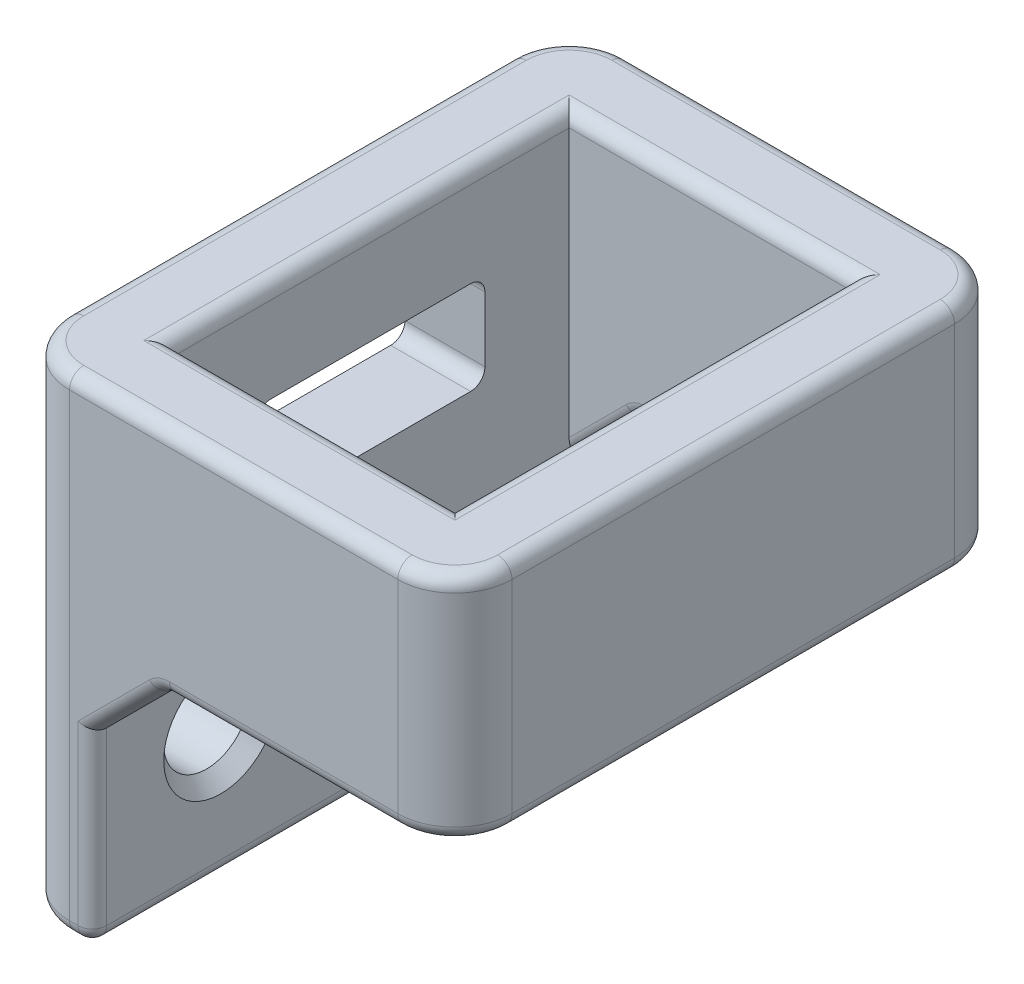
from build123d import *

# Parameters (mm, degrees)
SKETCH1_W                      = 15.5
SKETCH1_H                      = 19.5
SKETCH1_W_2                    = 9.9
SKETCH1_H_2                    = 13.9
BOSS_EXTRUDE1_DEPTH            = 4.05
SKETCH2_W                      = 19.5
SKETCH2_H                      = 9
SKETCH2_R                      = 1.5
BOSS_EXTRUDE2_DEPTH            = 2.8
CHAMFER1_SIZE                  = 2.5
FILLET1_R                      = 2
FILLET2_R                      = 0.5
CHAMFER2_SIZE                  = 0.5
CUT_EXTRUDE1_DEPTH             = 1.0000001
CUT_EXTRUDE1_DIRECTION_2_REACH = 17.5


with BuildPart() as part:
    # Sketch1 → Boss-Extrude1 (new body, symmetric)
    with BuildSketch(Plane(origin=(0, 0, 0), x_dir=(1, 0, 0), z_dir=(0, 1, 0))):
        Rectangle(SKETCH1_W, SKETCH1_H)
        Rectangle(SKETCH1_W_2, SKETCH1_H_2, mode=Mode.SUBTRACT)
    extrude(amount=BOSS_EXTRUDE1_DEPTH, both=True)

    # Sketch2 → Boss-Extrude2 (add)
    with BuildSketch(Plane.ZY.offset(7.75)):
        with Locations((0, -8.55)):
            Rectangle(SKETCH2_W, SKETCH2_H)
        with Locations((-5.25, -8.55)):
            Circle(SKETCH2_R, mode=Mode.SUBTRACT)
        with Locations((5.25, -8.55)):
            Circle(SKETCH2_R, mode=Mode.SUBTRACT)
    extrude(amount=-BOSS_EXTRUDE2_DEPTH)

    # Chamfer1
    chamfer1_edges = [part.edges().sort_by_distance(p)[0] for p in [
        (-4.95, -4.05, -8.35),
        (-4.95, -4.05, 8.35),
    ]]
    chamfer(chamfer1_edges, length=CHAMFER1_SIZE)

    # Fillet1
    fillet1_edges = [part.edges().sort_by_distance(p)[0] for p in [
        (-7.75, -4.5, -9.75),
        (7.75, 0, -9.75),
        (7.75, 0, 9.75),
        (-7.75, -4.5, 9.75),
    ]]
    fillet(fillet1_edges, radius=FILLET1_R)

    # Fillet2
    fillet2_edges = [part.edges().sort_by_distance(p)[0] for p in [
        (4.95, -4.05, 0),
        (1.25, -4.05, -6.95),
        (-4.95, 4.05, 0),
        (0, 4.05, 6.95),
        (4.95, 4.05, 0),
        (0, 4.05, -6.95),
        (-5.35, -13.05, -9.75),
        (-4.95, -9.8, 9.75),
        (-4.95, -13.05, 0),
        (-5.35, -13.05, 9.75),
        (1.65, -4.05, 9.75),
        (1.25, -4.05, 6.95),
        (-2.45, -4.05, 8.35),
        (-2.45, -4.05, -8.35),
        (-4.95, -9.8, -9.75),
        (-3.7, -5.3, -9.75),
        (-3.7, -5.3, -6.95),
        (-3.7, -5.3, 6.95),
        (-3.7, -5.3, 9.75),
        (1.65, -4.05, -9.75),
        (0, 4.05, -9.75),
        (7.75, -4.05, 0),
        (7.164213562, -4.05, 9.164213562),
        (7.164213562, -4.05, -9.164213562),
        (7.75, 4.05, 0),
        (-7.75, 4.05, 0),
        (0, 4.05, 9.75),
        (-7.164213562, 4.05, 9.164213562),
        (-7.164213562, 4.05, -9.164213562),
        (7.164213562, 4.05, 9.164213562),
        (7.164213562, 4.05, -9.164213562),
        (-7.75, -13.05, 0),
        (-7.164213562, -13.05, 9.164213562),
        (-7.164213562, -13.05, -9.164213562),
    ]]
    fillet(fillet2_edges, radius=FILLET2_R)

    # Chamfer2
    chamfer2_edges = [part.edges().sort_by_distance(p)[0] for p in [
        (-4.95, -8.55, 3.75),
        (-4.95, -8.55, -6.75),
    ]]
    chamfer(chamfer2_edges, length=CHAMFER2_SIZE)

    # Sketch3 → Cut-Extrude1 (cut)
    with BuildSketch(Plane.ZY.offset(7.75)):
        with BuildLine():
            Line((-3.5, 0.55), (3.5, 0.55))
            ThreePointArc((3.5, 0.55), (3.853553391, 0.403553391), (4, 0.05))
            Line((4, 0.05), (4, -2.22))
            ThreePointArc((4, -2.22), (3.853553391, -2.573553391), (3.5, -2.72))
            Line((3.5, -2.72), (-3.5, -2.72))
            ThreePointArc((-3.5, -2.72), (-3.853553391, -2.573553391), (-4, -2.22))
            Line((-4, -2.22), (-4, 0.05))
            ThreePointArc((-4, 0.05), (-3.853553391, 0.403553391), (-3.5, 0.55))
        make_face()
    extrude(amount=CUT_EXTRUDE1_DEPTH, mode=Mode.SUBTRACT)

    # Sketch3 → Cut-Extrude1 direction 2 (cut, up to next)
    with BuildSketch(Plane.ZY.offset(7.75), mode=Mode.PRIVATE) as cut_extrude1_direction_2_sk1:
        with BuildLine():
            Line((-3.5, 0.55), (3.5, 0.55))
            ThreePointArc((3.5, 0.55), (3.853553391, 0.403553391), (4, 0.05))
            Line((4, 0.05), (4, -2.22))
            ThreePointArc((4, -2.22), (3.853553391, -2.573553391), (3.5, -2.72))
            Line((3.5, -2.72), (-3.5, -2.72))
            ThreePointArc((-3.5, -2.72), (-3.853553391, -2.573553391), (-4, -2.22))
            Line((-4, -2.22), (-4, 0.05))
            ThreePointArc((-4, 0.05), (-3.853553391, 0.403553391), (-3.5, 0.55))
        make_face()
    cut_extrude1_direction_2_tool1 = extrude(cut_extrude1_direction_2_sk1.sketch, amount=-CUT_EXTRUDE1_DIRECTION_2_REACH, mode=Mode.PRIVATE) & part.part
    add(cut_extrude1_direction_2_tool1.solids().sort_by_distance((-7.75, -1.085, 0))[0], mode=Mode.SUBTRACT)


solid = part.part
